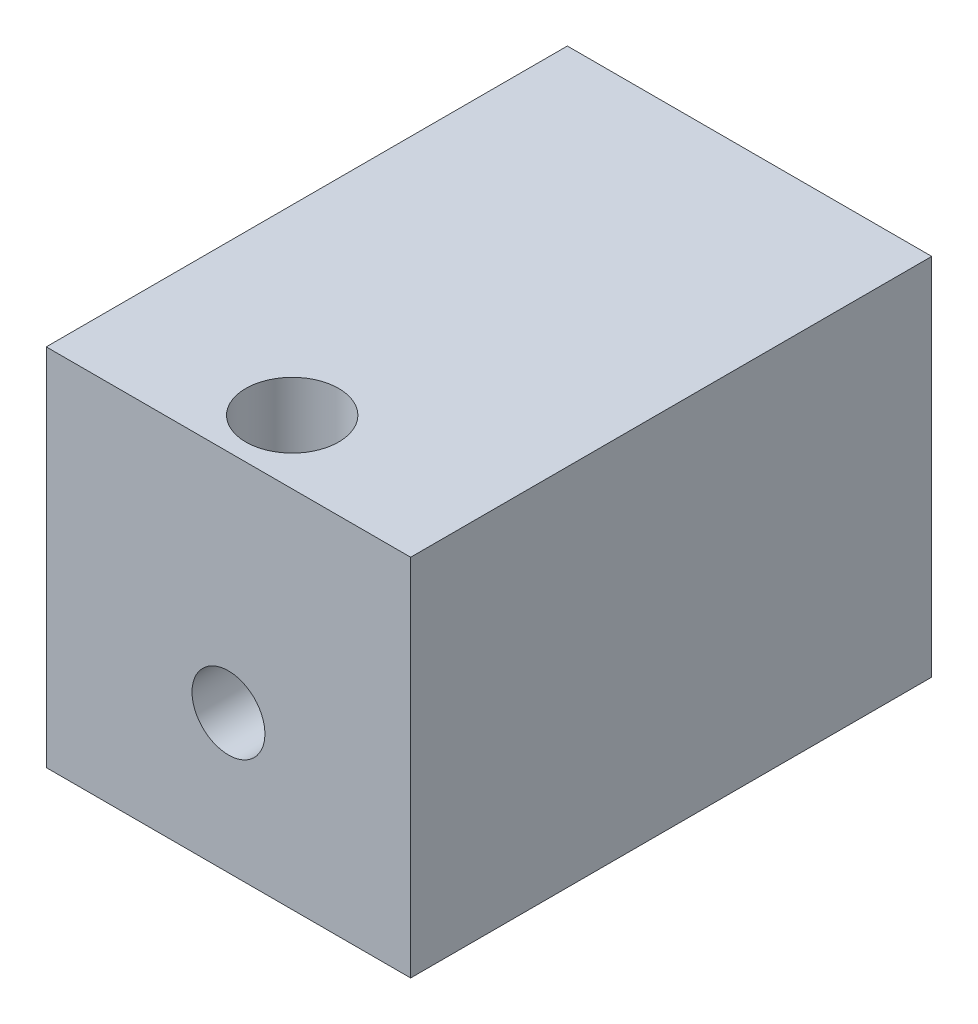
from build123d import *

# Parameters (mm, degrees)
SKETCH1_W                       = 20
SKETCH1_H                       = 28.6
BOSS_EXTRUDE1_DEPTH             = 20
SKETCH2_R                       = 7.6
CUT_EXTRUDE1_DEPTH              = 13
SKETCH3_R                       = 2
CUT_EXTRUDE2_DEPTH              = 28.6
SKIZZE1_R                       = 2.55
SCHNITT_LINEAR_AUSTRAGEN1_DEPTH = 8


with BuildPart() as part:
    # Sketch1 → Boss-Extrude1 (new body)
    with BuildSketch(Plane(origin=(0, 0, 0), x_dir=(1, 0, 0), z_dir=(0, 1, 0))):
        with Locations((10, 14.3)):
            Rectangle(SKETCH1_W, SKETCH1_H)
    extrude(amount=BOSS_EXTRUDE1_DEPTH)

    # Sketch2 → Cut-Extrude1 (cut)
    with BuildSketch(Plane.XZ):
        with Locations((10, -18.6)):
            Circle(SKETCH2_R)
    extrude(amount=-CUT_EXTRUDE1_DEPTH, mode=Mode.SUBTRACT)

    # Sketch3 → Cut-Extrude2 (cut)
    with BuildSketch(Plane(origin=(0, 0, -28.6), x_dir=(-1, 0, 0), z_dir=(0, 0, -1))):
        with Locations((-10, 7.6)):
            Circle(SKETCH3_R)
    extrude(amount=-CUT_EXTRUDE2_DEPTH, mode=Mode.SUBTRACT)

    # Skizze1 → Schnitt-Linear austragen1 (cut)
    with BuildSketch(Plane(origin=(0, 20, 0), x_dir=(1, 0, 0), z_dir=(0, 1, 0))):
        with Locations((10, 3.5)):
            Circle(SKIZZE1_R)
    extrude(amount=-SCHNITT_LINEAR_AUSTRAGEN1_DEPTH, mode=Mode.SUBTRACT)


solid = part.part
